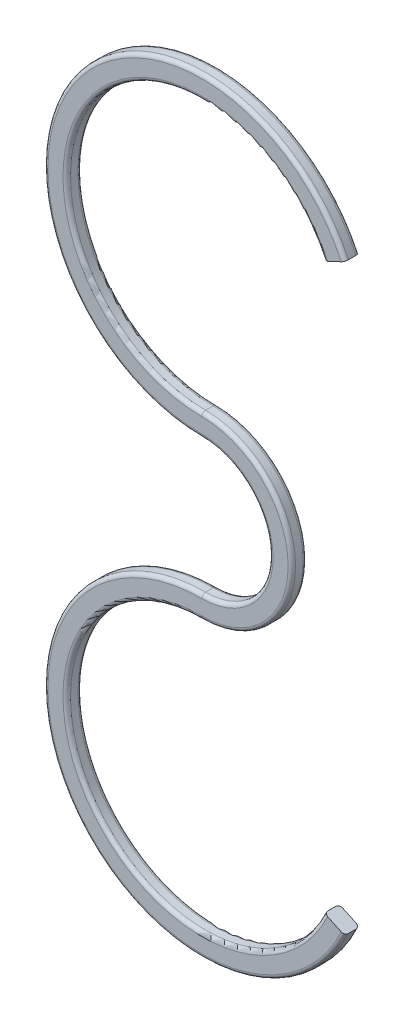
from build123d import *

# Parameters (mm, degrees)
EXTRUDE_THIN1_DEPTH = 1
FILLET1_R           = 0.25


with BuildPart() as part:
    # Sketch1 → Extrude-Thin1 (new body)
    with BuildSketch(Plane.XY):
        with BuildLine():
            ThreePointArc((8.156770083, 18.803564356), (-7.590523012, 19.835696475), (0, 6))
            ThreePointArc((0, 6), (4.242640687, 4.242640687), (6, 0))
            ThreePointArc((6, 0), (4.242640687, -4.242640687), (0, -6))
            ThreePointArc((0, -6), (-7.590523012, -19.835696475), (8.156770083, -18.803564356))
            Line((8.156770083, -18.803564356), (9.516231764, -19.437491748))
            ThreePointArc((9.516231764, -19.437491748), (-8.855610181, -20.641645888), (0, -4.5))
            ThreePointArc((0, -4.5), (3.181980515, -3.181980515), (4.5, 0))
            ThreePointArc((4.5, 0), (3.181980515, 3.181980515), (0, 4.5))
            ThreePointArc((0, 4.5), (-8.855610181, 20.641645888), (9.516231764, 19.437491748))
            Line((9.516231764, 19.437491748), (8.156770083, 18.803564356))
        make_face()
    extrude(amount=EXTRUDE_THIN1_DEPTH)

    # Fillet1
    fillet1_edges = [part.edges().sort_by_distance(p)[0] for p in [
        (-8.855610181, -20.641645888, 0),
        (4.5, 0, 0),
        (-8.855610181, 20.641645888, 0),
        (-7.590523012, 19.835696475, 0),
        (-8.855610181, 20.641645888, 1),
        (4.5, 0, 1),
        (-8.855610181, -20.641645888, 1),
        (-7.590523012, -19.835696475, 1),
        (6, 0, 1),
        (-7.590523012, 19.835696475, 1),
        (6, 0, 0),
        (-7.590523012, -19.835696475, 0),
    ]]
    fillet(fillet1_edges, radius=FILLET1_R)


solid = part.part
